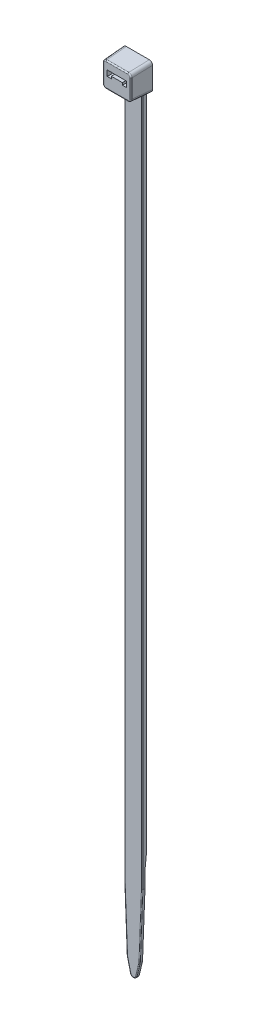
from build123d import *

# Parameters (mm, degrees)
BOSS_EXTRUDE1_DEPTH             = 2.215
BOSS_EXTRUDE3_REACH             = 201.5
BOSS_EXTRUDE3_START             = -1
BOSS_EXTRUDE3_DIRECTION_2_REACH = 3
CUT_EXTRUDE1_DEPTH              = 5.2
CUT_EXTRUDE2_DEPTH              = 0.7
FILLET1_R                       = 2
FILLET2_R                       = 0.8
FILLET4_R                       = 0.2
FILLET3_R                       = 0.5
FILLET5_R                       = 0.3


with BuildPart() as part:
    # Sketch1 → Boss-Extrude1 (new body, symmetric)
    with BuildSketch(Plane(origin=(0, 0, 0), x_dir=(0, 0, -1), z_dir=(1, 0, 0))):
        Polygon((0, 0), (-5.2, -0.325), (-5.2, -6.475), (-1.13, -6.729375), (-1.13, -198.5), (-0.43, -198.5), (-0.43, -174.5), (0, -170.5), align=None)
    extrude(amount=BOSS_EXTRUDE1_DEPTH, both=True)

    # Boss-Extrude3: up to this face of the body (flat: up to its plane)
    boss_extrude3_end = Plane(part.part.faces().sort_by_distance((0, -6.6021875, 3.165))[0])
    # Sketch2 → Boss-Extrude3 (add, up to the picked face)
    with BuildSketch(Plane(origin=(0, 0, 0), x_dir=(1, 0, 0), z_dir=(0, 1, 0)).offset(BOSS_EXTRUDE3_START), mode=Mode.PRIVATE) as boss_extrude3_sk1:
        Polygon((-3.66, 0), (3.66, 0), (3.5, -5.2), (-3.5, -5.2), align=None)
    boss_extrude3_tool1 = split(extrude(boss_extrude3_sk1.sketch, amount=-BOSS_EXTRUDE3_REACH, mode=Mode.PRIVATE), bisect_by=boss_extrude3_end, keep=Keep.BOTH, mode=Mode.PRIVATE)
    add(boss_extrude3_tool1.solids().sort_by_distance((0, -1, 2.580633))[0])

    # Boss-Extrude3 direction 2: up to this face of the body (flat: up to its plane)
    boss_extrude3_direction_2_end = Plane(part.part.faces().sort_by_distance((0, -0.1625, 2.6))[0])
    # Sketch2 → Boss-Extrude3 direction 2 (add, up to the picked face)
    with BuildSketch(Plane(origin=(0, 0, 0), x_dir=(1, 0, 0), z_dir=(0, 1, 0)).offset(BOSS_EXTRUDE3_START), mode=Mode.PRIVATE) as boss_extrude3_direction_2_sk1:
        Polygon((-3.66, 0), (3.66, 0), (3.5, -5.2), (-3.5, -5.2), align=None)
    boss_extrude3_direction_2_tool1 = split(extrude(boss_extrude3_direction_2_sk1.sketch, amount=BOSS_EXTRUDE3_DIRECTION_2_REACH, mode=Mode.PRIVATE), bisect_by=boss_extrude3_direction_2_end, keep=Keep.BOTH, mode=Mode.PRIVATE)
    add(boss_extrude3_direction_2_tool1.solids().sort_by_distance((0, -1, 2.580633))[0])

    # Sketch3 → Cut-Extrude1 (cut)
    with BuildSketch(Plane.XY.offset(5.2)):
        Polygon((-2.4, -2.225), (2.4, -2.225), (2.4, -3.625), (1.375, -3.625), (1.375, -3.075), (-1.375, -3.075), (-1.375, -3.625), (-2.4, -3.625), align=None)
    extrude(amount=-CUT_EXTRUDE1_DEPTH, mode=Mode.SUBTRACT)

    # Sketch5 → Cut-Extrude2 (cut)
    with BuildSketch(Plane.XY.offset(1.13)):
        with BuildLine():
            Line((0.777423831, -197.888711915), (1.6, -194.5))
            Line((1.6, -194.5), (2.215, -178.5))
            Line((2.215, -178.5), (2.215, -198.6))
            Line((2.215, -198.6), (-2.215, -198.6))
            Line((-2.215, -198.6), (-2.215, -178.5))
            Line((-2.215, -178.5), (-1.6, -194.5))
            Line((-1.6, -194.5), (-0.777423831, -197.888711915))
            ThreePointArc((-0.777423831, -197.888711915), (0, -198.5), (0.777423831, -197.888711915))
        make_face()
    extrude(amount=-CUT_EXTRUDE2_DEPTH, mode=Mode.SUBTRACT)

    # Fillet1
    fillet1_edges = [part.edges().sort_by_distance(p)[0] for p in [
        (2.215, -178.5, 0.78),
        (1.6, -194.5, 0.78),
        (-2.215, -178.5, 0.78),
        (-1.6, -194.5, 0.78),
    ]]
    fillet(fillet1_edges, radius=FILLET1_R)

    # Fillet2
    fillet2_edges = [part.edges().sort_by_distance(p)[0] for p in [
        (3.58, -0.1625, 2.6),
        (3.58, -6.6375, 2.6),
        (-3.58, -0.1625, 2.6),
        (-3.58, -6.6375, 2.6),
    ]]
    fillet(fillet2_edges, radius=FILLET2_R)

    # Fillet4
    fillet4_edges = [part.edges().sort_by_distance(p)[0] for p in [
        (1.165077859, -196.291719596, 1.13),
        (1.911348252, -186.399882881, 1.13),
        (-1.911348252, -186.399882881, 1.13),
        (1.590082395, -194.498619822, 1.13),
        (-1.590082395, -194.498619822, 1.13),
        (1.911348252, -186.399882881, 1.13),
        (-1.911348252, -186.399882881, 1.13),
        (2.215, -92.6146875, 1.13),
        (0, -198.5, 1.13),
        (-1.165077859, -196.291719596, 1.13),
        (-2.215, -92.6146875, 1.13),
    ]]
    fillet(fillet4_edges, radius=FILLET4_R)

    # Fillet3
    fillet3_edges = [part.edges().sort_by_distance(p)[0] for p in [
        (0, -6.729375, 1.13),
        (-2.215, -6.7709375, 0.465),
        (2.215, -6.7709375, 0.465),
        (-2.156490258, -6.733040474, 1.071352421),
        (2.156490258, -6.733040474, 1.071352421),
    ]]
    fillet(fillet3_edges, radius=FILLET3_R)

    # Fillet5
    fillet5_edges = [part.edges().sort_by_distance(p)[0] for p in [
        (0, -6.475, 5.2),
        (-3.5, -3.4, 5.2),
        (0, -0.325, 5.2),
        (3.5, -3.4, 5.2),
        (3.266325663, -6.240562729, 5.2),
        (3.266325663, -0.559437271, 5.2),
        (-3.266325663, -0.559437271, 5.2),
        (-3.266325663, -6.240562729, 5.2),
    ]]
    fillet(fillet5_edges, radius=FILLET5_R)


solid = part.part
